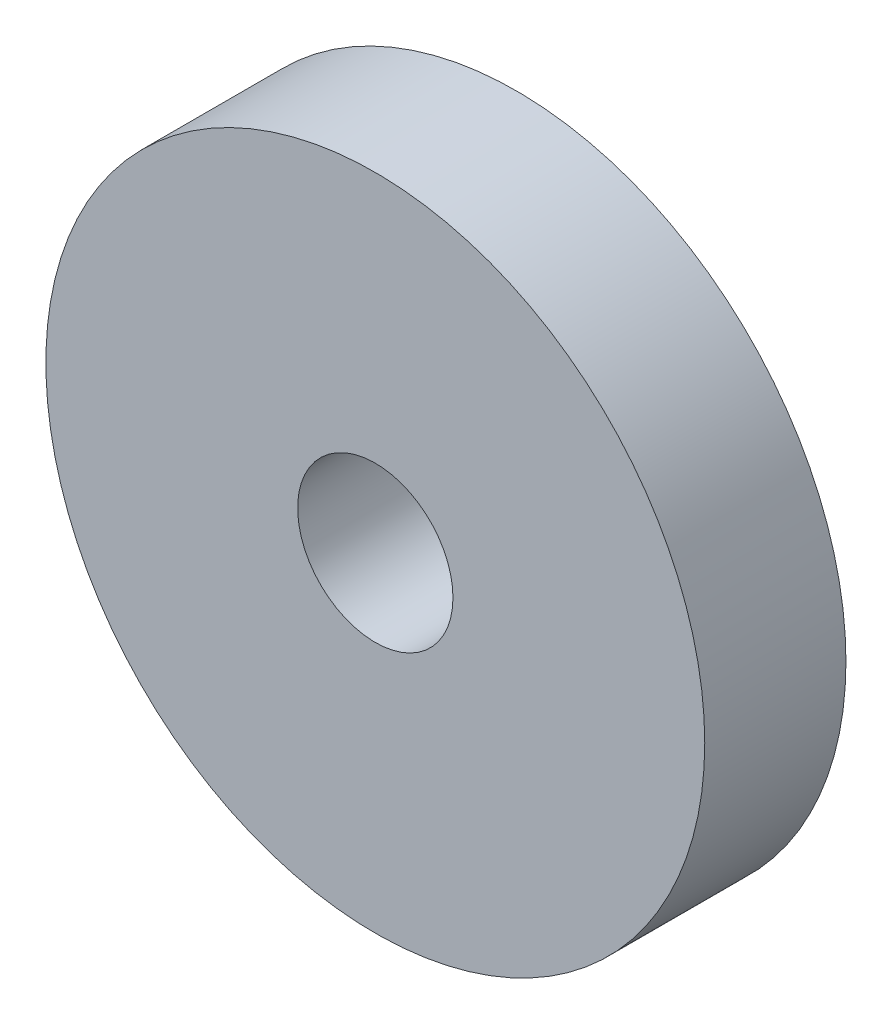
from build123d import *

# Parameters (mm, degrees)
SKETCH1_R           = 7
BOSS_EXTRUDE1_DEPTH = 3
SKETCH2_R           = 1.65
CUT_EXTRUDE1_DEPTH  = 3


with BuildPart() as part:
    # Sketch1 → Boss-Extrude1 (new body)
    with BuildSketch(Plane.XY):
        Circle(SKETCH1_R)
    extrude(amount=BOSS_EXTRUDE1_DEPTH)

    # Sketch2 → Cut-Extrude1 (cut)
    with BuildSketch(Plane.XY.offset(3)):
        Circle(SKETCH2_R)
    extrude(amount=-CUT_EXTRUDE1_DEPTH, mode=Mode.SUBTRACT)


solid = part.part
